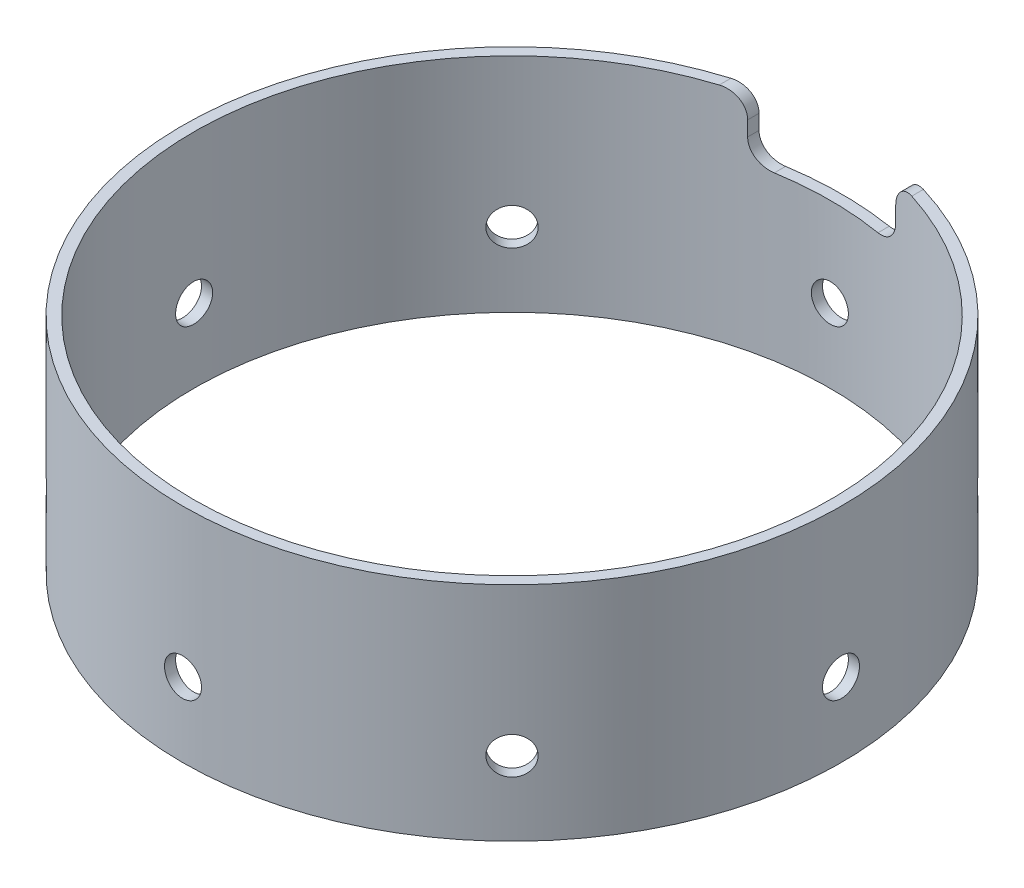
from build123d import *

# Parameters (mm, degrees)
SKIZZE1_R                       = 44.5
SKIZZE1_R_2                     = 43
AUFSATZ_LINEAR_AUSTRAGEN1_DEPTH = 30
SKIZZE3_R                       = 2.5
SCHNITT_LINEAR_AUSTRAGEN1_DEPTH = 45.5
KREISMUSTER1_COUNT              = 8
SCHNITT_LINEAR_AUSTRAGEN2_DEPTH = 45.500000122


with BuildPart() as part:
    # Skizze1 → Aufsatz-Linear austragen1 (new body)
    with BuildSketch(Plane(origin=(0, 0, 0), x_dir=(1, 0, 0), z_dir=(0, 1, 0))):
        Circle(SKIZZE1_R)
        Circle(SKIZZE1_R_2, mode=Mode.SUBTRACT)
    extrude(amount=AUFSATZ_LINEAR_AUSTRAGEN1_DEPTH)

    # Skizze3 → Schnitt-Linear austragen1 (cut, through all)
    with BuildSketch(Plane.XY):
        with Locations((0, 10)):
            Circle(SKIZZE3_R)
    schnitt_linear_austragen1 = extrude(amount=-SCHNITT_LINEAR_AUSTRAGEN1_DEPTH, mode=Mode.SUBTRACT)

    # Kreismuster1: Schnitt-Linear austragen1 ×8 about axis
    kreismuster1_axis = Axis((0, 30, 0), (0, -1, 0))
    for i in range(1, KREISMUSTER1_COUNT):
        add(schnitt_linear_austragen1.rotate(kreismuster1_axis, i * 360 / KREISMUSTER1_COUNT), mode=Mode.SUBTRACT)

    # Skizze4 → Schnitt-Linear austragen2 (cut, through all)
    with BuildSketch(Plane.XY):
        with BuildLine():
            Line((-13, 30), (13, 30))
            ThreePointArc((13, 30), (10.878679656, 29.121320344), (10, 27))
            Line((10, 27), (10, 25))
            ThreePointArc((10, 25), (9.121320344, 22.878679656), (7, 22))
            Line((7, 22), (-7, 22))
            ThreePointArc((-7, 22), (-9.121320344, 22.878679656), (-10, 25))
            Line((-10, 25), (-10, 27))
            ThreePointArc((-10, 27), (-10.878679656, 29.121320344), (-13, 30))
        make_face()
    extrude(amount=-SCHNITT_LINEAR_AUSTRAGEN2_DEPTH, mode=Mode.SUBTRACT)


solid = part.part
